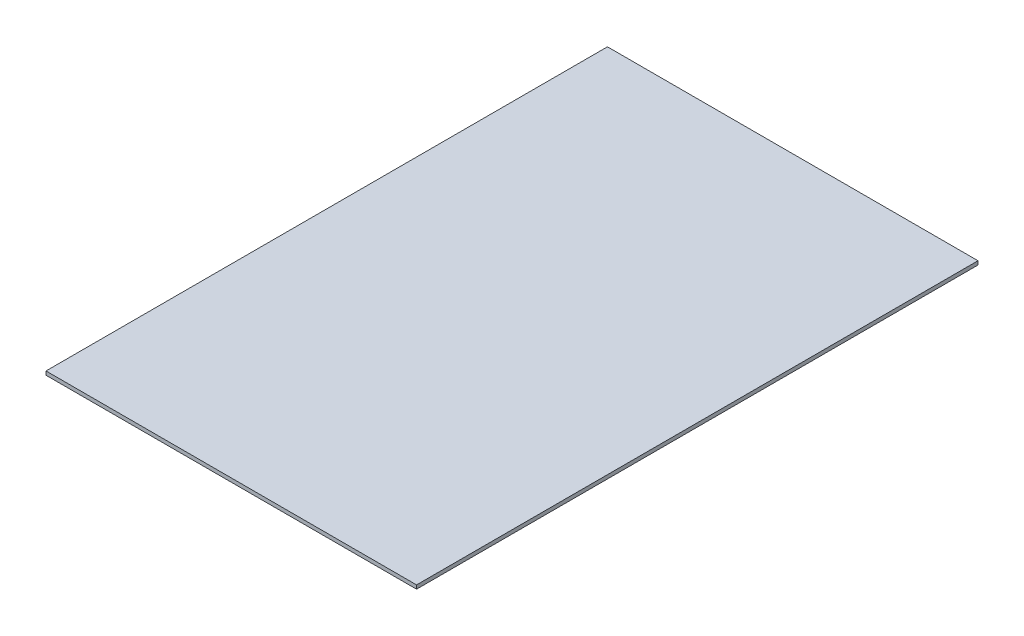
from build123d import *

# Parameters (mm, degrees)
SKETCH1_W           = 198
SKETCH1_H           = 300
BOSS_EXTRUDE1_DEPTH = 2


with BuildPart() as part:
    # Sketch1 → Boss-Extrude1 (new body)
    with BuildSketch(Plane(origin=(0, 0, 0), x_dir=(1, 0, 0), z_dir=(0, 1, 0))):
        Rectangle(SKETCH1_W, SKETCH1_H)
    extrude(amount=BOSS_EXTRUDE1_DEPTH)


solid = part.part
